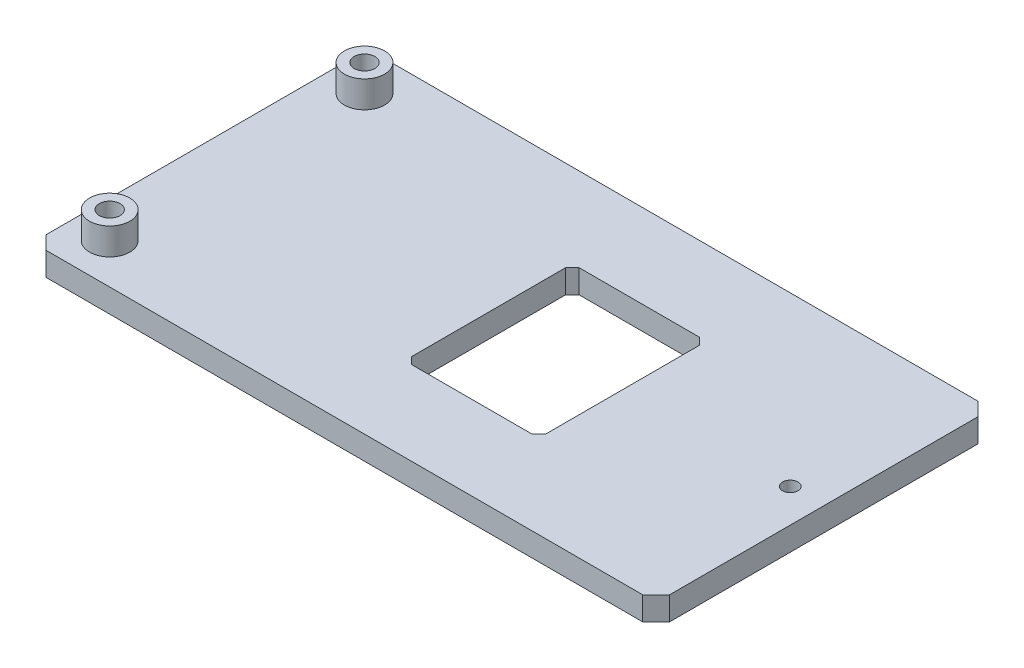
from build123d import *

# Parameters (mm, degrees)
SKETCH1_R                = 1.15
SKETCH1_R_2              = 1.55
BOSS_EXTRUDE1_DEPTH      = 3
BOSS_EXTRUDE1_DEPTH_BACK = 0.506598952
SKETCH2_R                = 3
SKETCH2_R_2              = 1.55
BOSS_EXTRUDE2_DEPTH      = 4


with BuildPart() as part:
    # Sketch1 → Boss-Extrude1 (new body, two sides)
    with BuildSketch(Plane(origin=(0, 0, 0), x_dir=(1, 0, 0), z_dir=(0, 1, 0))) as boss_extrude1_sk:
        Polygon((-48.674262421, -25), (40.325737579, -25), (42.325737579, -23), (42.325737579, 23), (40.325737579, 25), (-48.674262421, 25), (-50.674262421, 23), (-50.674262421, -23), align=None)
        with Locations((37.325737579, 0)):
            Circle(SKETCH1_R, mode=Mode.SUBTRACT)
        with Locations((-45.174262421, 19)):
            Circle(SKETCH1_R_2, mode=Mode.SUBTRACT)
        with Locations((-45.174262421, -19)):
            Circle(SKETCH1_R_2, mode=Mode.SUBTRACT)
        Polygon((-6.674262421, -12.5), (11.325737579, -12.5), (12.325737579, -11.5), (12.325737579, 11.5), (11.325737579, 12.5), (-6.674262421, 12.5), (-7.674262421, 11.5), (-7.674262421, -11.5), align=None, mode=Mode.SUBTRACT)
    extrude(amount=BOSS_EXTRUDE1_DEPTH)
    extrude(boss_extrude1_sk.sketch, amount=-BOSS_EXTRUDE1_DEPTH_BACK)

    # Sketch2 → Boss-Extrude2 (add)
    with BuildSketch(Plane(origin=(0, 3, 0), x_dir=(1, 0, 0), z_dir=(0, 1, 0))):
        with Locations((-45.174262421, 19)):
            Circle(SKETCH2_R)
        with Locations((-45.174262421, 19)):
            Circle(SKETCH2_R_2, mode=Mode.SUBTRACT)
        with Locations((-45.174262421, -19)):
            Circle(SKETCH2_R)
        with Locations((-45.174262421, -19)):
            Circle(SKETCH2_R_2, mode=Mode.SUBTRACT)
    extrude(amount=BOSS_EXTRUDE2_DEPTH)


solid = part.part
